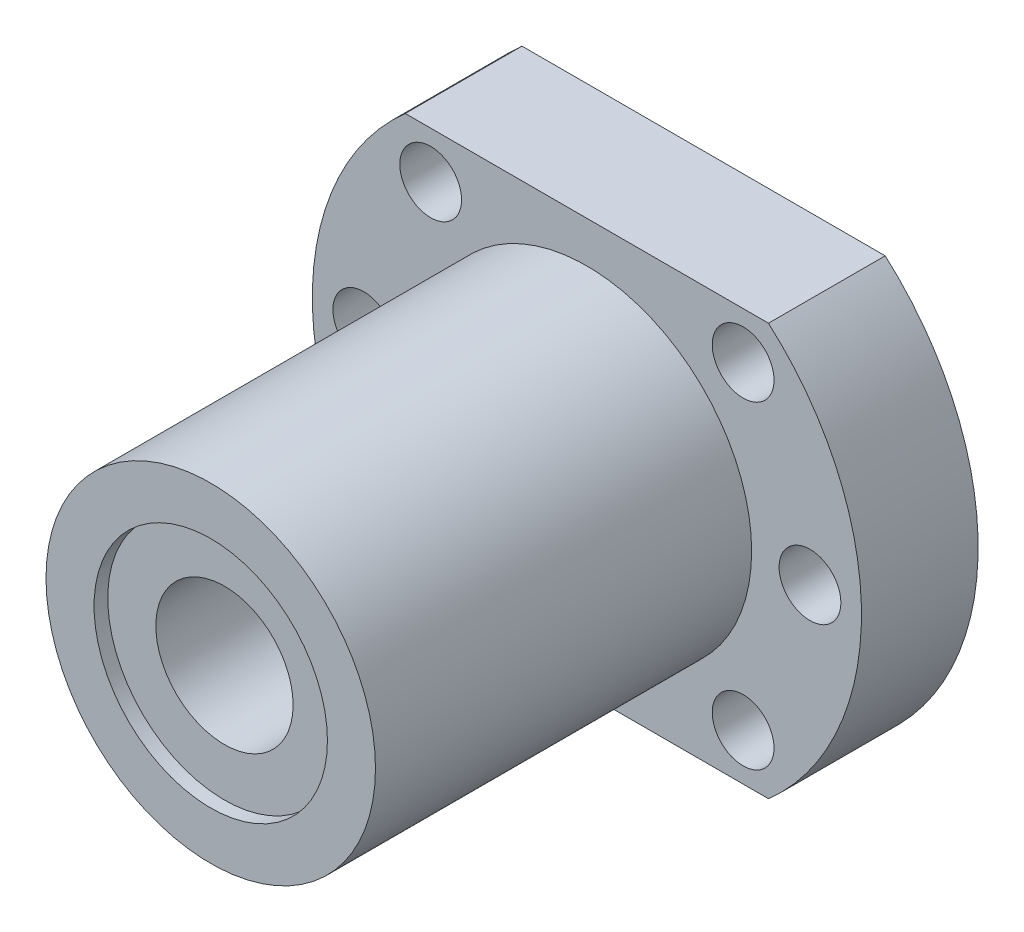
from build123d import *

# Parameters (mm, degrees)
SALIENTE_EXTRUIR1_DEPTH = 8.5
CROQUIS2_R              = 12
SALIENTE_EXTRUIR2_DEPTH = 27.4
CROQUIS3_R              = 5
CORTAR_EXTRUIR1_DEPTH   = 35.9
CROQUIS4_R              = 8.5
CORTAR_EXTRUIR2_DEPTH   = 1
CROQUIS5_R              = 8.5
CORTAR_EXTRUIR3_DEPTH   = 1
CROQUIS6_R              = 2.25
CORTAR_EXTRUIR4_DEPTH   = 8.5


with BuildPart() as part:
    # Croquis1 → Saliente-Extruir1 (new body)
    with BuildSketch(Plane.XY):
        with BuildLine():
            Line((-13.228756555, 15), (13.228756555, 15))
            ThreePointArc((13.228756555, 15), (20, 0), (13.228756555, -15))
            Line((13.228756555, -15), (-13.228756555, -15))
            ThreePointArc((-13.228756555, -15), (-20, 0), (-13.228756555, 15))
        make_face()
    extrude(amount=SALIENTE_EXTRUIR1_DEPTH)

    # Croquis2 → Saliente-Extruir2 (add)
    with BuildSketch(Plane.XY.offset(8.5)):
        Circle(CROQUIS2_R)
    extrude(amount=SALIENTE_EXTRUIR2_DEPTH)

    # Croquis3 → Cortar-Extruir1 (cut)
    with BuildSketch(Plane.XY.offset(35.9)):
        Circle(CROQUIS3_R)
    extrude(amount=-CORTAR_EXTRUIR1_DEPTH, mode=Mode.SUBTRACT)

    # Croquis4 → Cortar-Extruir2 (cut)
    with BuildSketch(Plane.XY.offset(35.9)):
        Circle(CROQUIS4_R)
    extrude(amount=-CORTAR_EXTRUIR2_DEPTH, mode=Mode.SUBTRACT)

    # Croquis5 → Cortar-Extruir3 (cut)
    with BuildSketch(Plane(origin=(0, 0, 0), x_dir=(-1, 0, 0), z_dir=(0, 0, -1))):
        Circle(CROQUIS5_R)
    extrude(amount=-CORTAR_EXTRUIR3_DEPTH, mode=Mode.SUBTRACT)

    # Croquis6 → Cortar-Extruir4 (cut)
    with BuildSketch(Plane(origin=(0, 0, 0), x_dir=(-1, 0, 0), z_dir=(0, 0, -1))):
        with Locations((11.37991652, -11.6)):
            Circle(CROQUIS6_R)
        with Locations((16.25, 0)):
            Circle(CROQUIS6_R)
        with Locations((11.37991652, 11.6)):
            Circle(CROQUIS6_R)
        with Locations((-11.37991652, -11.6)):
            Circle(CROQUIS6_R)
        with Locations((-16.25, 0)):
            Circle(CROQUIS6_R)
        with Locations((-11.37991652, 11.6)):
            Circle(CROQUIS6_R)
    extrude(amount=-CORTAR_EXTRUIR4_DEPTH, mode=Mode.SUBTRACT)


solid = part.part
